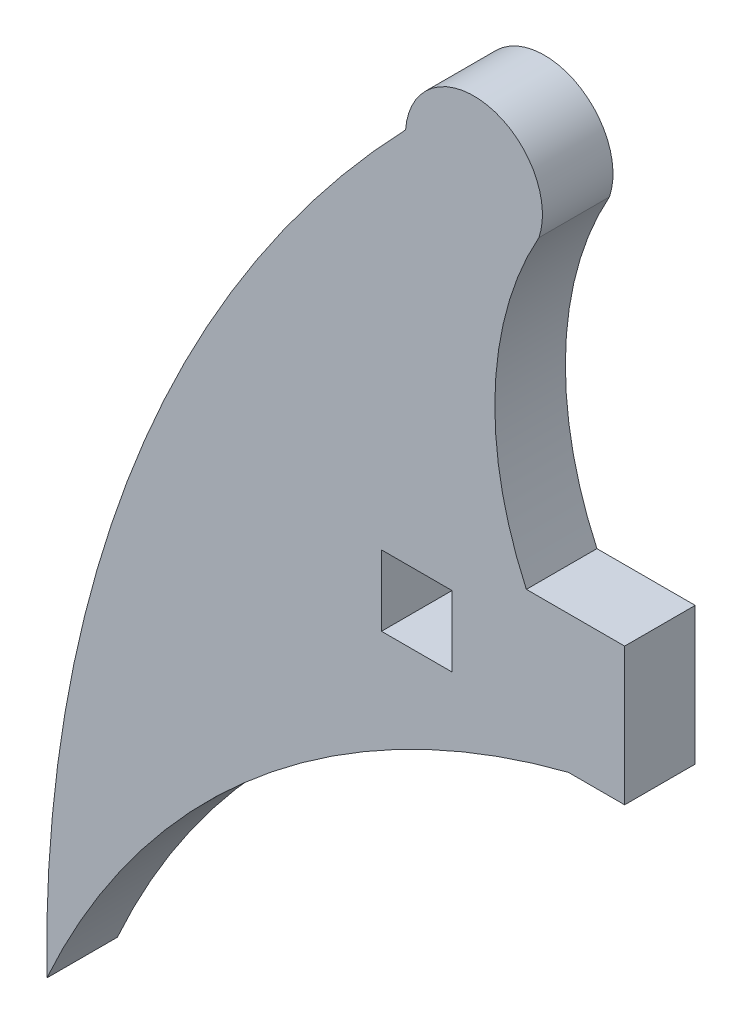
from build123d import *

# Parameters (mm, degrees)
SKETCH1_W           = 1.524
SKETCH1_H           = 1.524
BOSS_EXTRUDE1_DEPTH = 1.524


with BuildPart() as part:
    # Sketch1 → Boss-Extrude1 (new body)
    with BuildSketch(Plane.XY):
        with BuildLine():
            Line((-22.225726205, -1.524), (-22.225726205, -2.14505284))
            Line((-22.225726205, -2.14505284), (-23.442995373, -2.14505284))
            ThreePointArc((-23.442995373, -2.14505284), (-30.161746406, -5.595987037), (-34.709680239, -11.626481223))
            ThreePointArc((-34.709680239, -11.626481223), (-32.790024922, -0.986396807), (-26.958529189, 8.1180049))
            ThreePointArc((-26.958529189, 8.1180049), (-25.191828644, 9.462219786), (-24.078033866, 7.541905835))
            ThreePointArc((-24.078033866, 7.541905835), (-25.02470469, 4.216402452), (-24.348732091, 0.8255))
            Line((-24.348732091, 0.8255), (-22.225726205, 0.8255))
            Line((-22.225726205, 0.8255), (-22.225726205, -1.524))
        make_face()
        with Locations((-26.716818925, -0.762)):
            Rectangle(SKETCH1_W, SKETCH1_H, mode=Mode.SUBTRACT)
    extrude(amount=BOSS_EXTRUDE1_DEPTH)


solid = part.part
